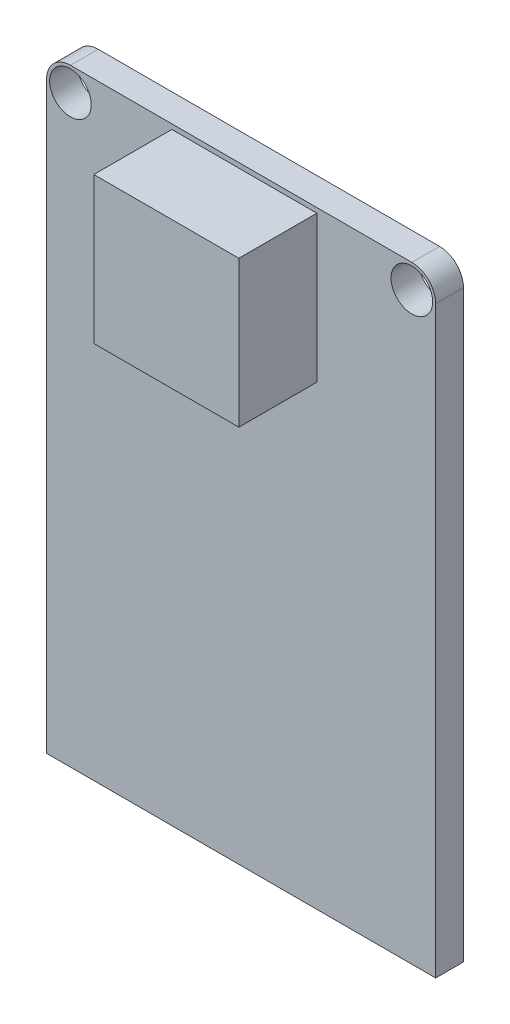
from build123d import *

# Parameters (mm, degrees)
SKETCH1_R           = 1.219603507
BOSS_EXTRUDE1_DEPTH = 1.6256
SKETCH2_W           = 8.4963
SKETCH2_H           = 8.5725
BOSS_EXTRUDE2_DEPTH = 4.572


with BuildPart() as part:
    # Sketch1 → Boss-Extrude1 (new body)
    with BuildSketch(Plane.XY):
        with BuildLine():
            Line((-11.39825, -17.8054), (11.39825, -17.8054))
            Line((11.39825, -17.8054), (11.39825, 16.4084))
            ThreePointArc((11.39825, 16.4084), (10.989078173, 17.396228173), (10.00125, 17.8054))
            Line((10.00125, 17.8054), (-10.00125, 17.8054))
            ThreePointArc((-10.00125, 17.8054), (-10.989078173, 17.396228173), (-11.39825, 16.4084))
            Line((-11.39825, 16.4084), (-11.39825, -17.8054))
        make_face()
        with Locations((-10.00125, 16.4084)):
            Circle(SKETCH1_R, mode=Mode.SUBTRACT)
        with Locations((10.00125, 16.4084)):
            Circle(SKETCH1_R, mode=Mode.SUBTRACT)
    extrude(amount=BOSS_EXTRUDE1_DEPTH)

    # Sketch2 → Boss-Extrude2 (add)
    with BuildSketch(Plane.XY.offset(1.6256)):
        with Locations((0.1905, 13.2334)):
            Rectangle(SKETCH2_W, SKETCH2_H)
    extrude(amount=BOSS_EXTRUDE2_DEPTH)


solid = part.part
